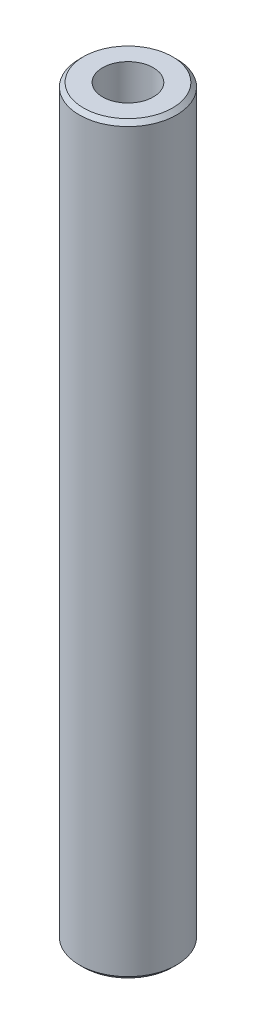
from build123d import *

# Parameters (mm, degrees)
CROQUIS2_R                = 4.7625
SALIENTE_EXTRUIR1_DEPTH   = 36.5125
CHAFL_N1_SIZE             = 0.396875
CLEARANCE_HOLE_DEPTH      = 38.128499414
CLEARANCE_HOLE_DEPTH_BACK = 38.128499414
CROQUIS4_R                = 2.4892


with BuildPart() as part:
    # Croquis2 → Saliente-Extruir1 (new, symmetric)
    with BuildSketch(Plane(origin=(0, 0, 0), x_dir=(1, 0, 0), z_dir=(0, 1, 0))):
        Circle(CROQUIS2_R)
    extrude(amount=SALIENTE_EXTRUIR1_DEPTH, both=True)

    # Chaflán1
    chafl_n1_edges = [part.edges().sort_by_distance(p)[0] for p in [
        (-4.7625, -36.5125, 0),
        (-4.7625, 36.5125, 0),
    ]]
    chamfer(chafl_n1_edges, length=CHAFL_N1_SIZE)

    # Croquis4 → Clearance Hole (cut, two sides: drawn at the far end of the back side and taken through both)
    with BuildSketch(Plane(origin=(0, 0, 0), x_dir=(1, 0, 0), z_dir=(0, 1, 0)).offset(-CLEARANCE_HOLE_DEPTH_BACK)):
        Circle(CROQUIS4_R)
    extrude(amount=CLEARANCE_HOLE_DEPTH + CLEARANCE_HOLE_DEPTH_BACK, mode=Mode.SUBTRACT)


solid = part.part
